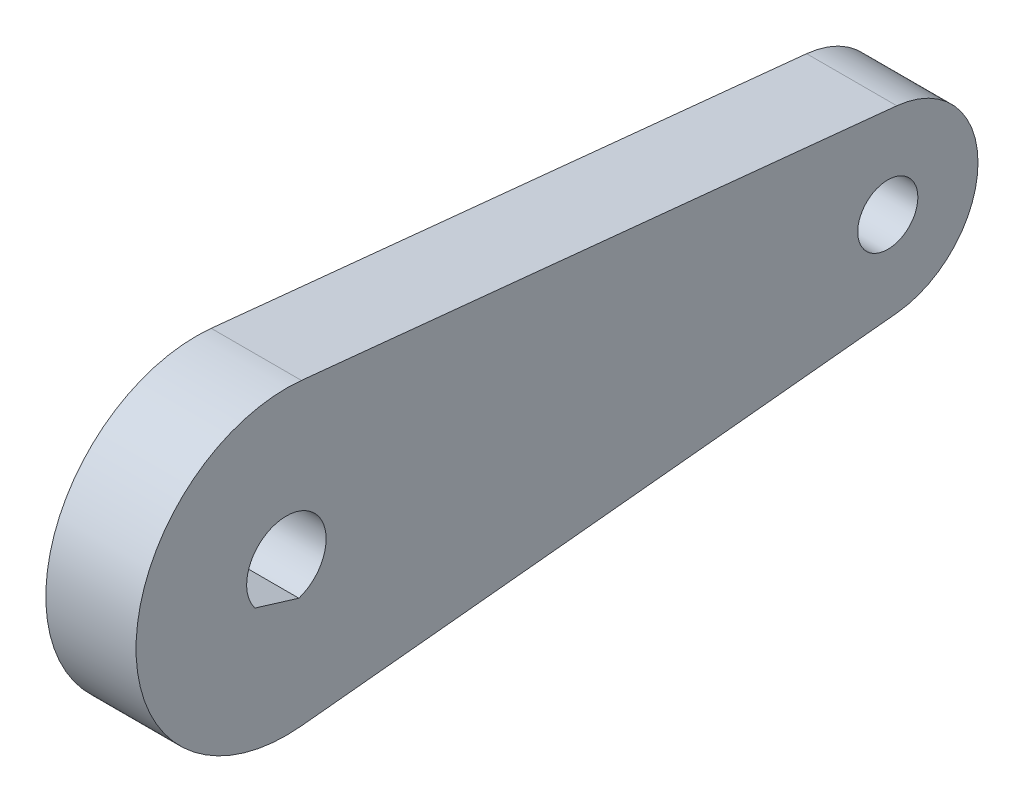
from build123d import *

# Parameters (mm, degrees)
SKETCH1_R                = 10
SKETCH1_R_2              = 6
BOSS_EXTRUDE1_DEPTH      = 3
BOSS_EXTRUDE1_DEPTH_BACK = 3
SKETCH2_R                = 2
CUT_EXTRUDE1_DEPTH       = 4
CUT_EXTRUDE1_DEPTH_BACK  = 4
CUT_EXTRUDE2_DEPTH       = 10


with BuildPart() as part:
    # Sketch1 → Boss-Extrude1 (new body, two sides)
    with BuildSketch(Plane(origin=(0, 0, 0), x_dir=(0, 0, -1), z_dir=(1, 0, 0))) as boss_extrude1_sk:
        Circle(SKETCH1_R)
        with BuildLine():
            Line((1, -9.949874371), (40.6, -5.969924623))
            ThreePointArc((40.6, -5.969924623), (34, 0), (40.6, 5.969924623))
            Line((40.6, 5.969924623), (1, 9.949874371))
            ThreePointArc((1, 9.949874371), (7.416198487, 6.708203932), (10, 0))
            ThreePointArc((10, 0), (7.416198487, -6.708203933), (1, -9.949874371))
        make_face()
        with Locations((40, 0)):
            Circle(SKETCH1_R_2)
    extrude(amount=BOSS_EXTRUDE1_DEPTH)
    extrude(boss_extrude1_sk.sketch, amount=-BOSS_EXTRUDE1_DEPTH_BACK)

    # Sketch2 → Cut-Extrude1 (cut, two sides)
    with BuildSketch(Plane(origin=(0, 0, 0), x_dir=(0, 0, -1), z_dir=(1, 0, 0))) as cut_extrude1_sk:
        with Locations((40, 0)):
            Circle(SKETCH2_R)
    extrude(amount=CUT_EXTRUDE1_DEPTH, mode=Mode.SUBTRACT)
    extrude(cut_extrude1_sk.sketch, amount=-CUT_EXTRUDE1_DEPTH_BACK, mode=Mode.SUBTRACT)

    # Sketch3 → Cut-Extrude2 (cut)
    with BuildSketch(Plane(origin=(3, 0, 0), x_dir=(0, 0, -1), z_dir=(1, 0, 0))):
        with BuildLine():
            Line((-2.09135741, -1.616067196), (0.829813276, -2.509354285))
            ThreePointArc((0.829813276, -2.509354285), (0.772893172, 2.527466151), (-2.09135741, -1.616067196))
        make_face()
    extrude(amount=-CUT_EXTRUDE2_DEPTH, mode=Mode.SUBTRACT)


solid = part.part
